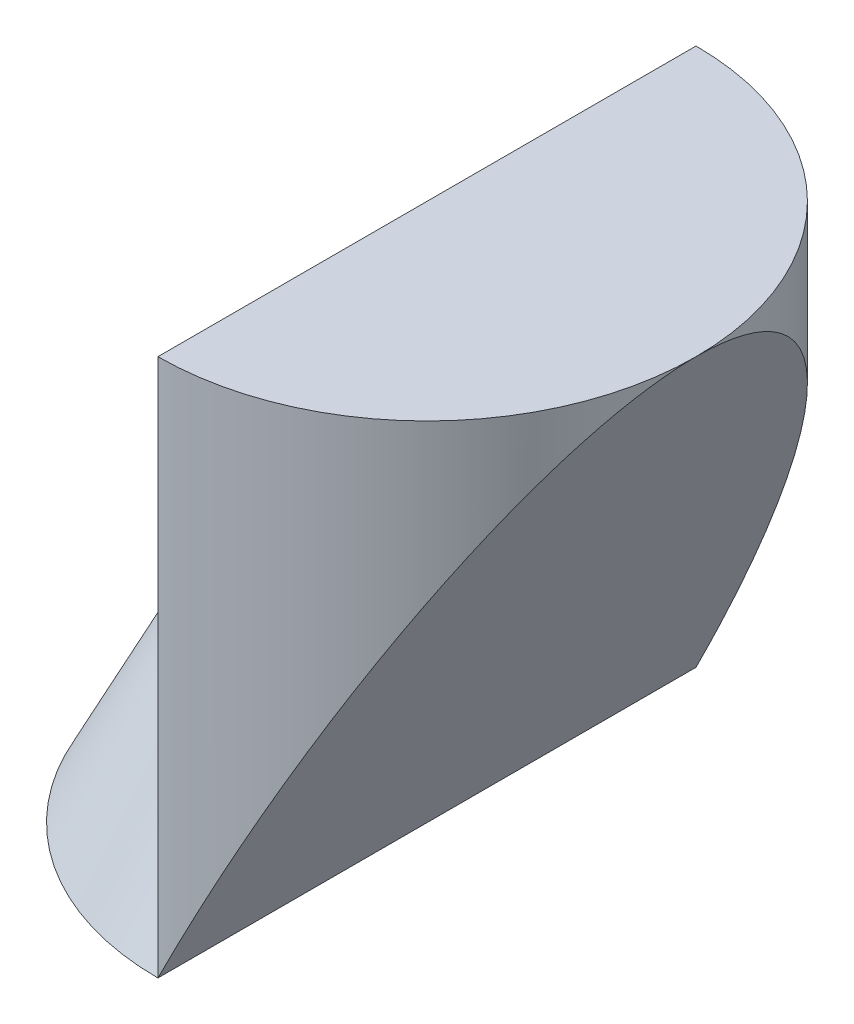
from build123d import *

# Parameters (mm, degrees)
BOSS_EXTRUDE1_DEPTH = 4
REVOLVE1_ANGLE      = 180
CUT_EXTRUDE4_DEPTH  = 4


with BuildPart() as part:
    # Sketch1 → Boss-Extrude1 (new body)
    with BuildSketch(Plane(origin=(0, 0, 0), x_dir=(1, 0, 0), z_dir=(0, 1, 0))):
        with BuildLine():
            Line((2, 0), (2, -4))
            ThreePointArc((2, -4), (4, -2), (2, 0))
        make_face()
    extrude(amount=BOSS_EXTRUDE1_DEPTH)

    # Sketch6 → Revolve1 (revolve)
    with BuildSketch(Plane.ZY.offset(-2)):
        Polygon((2, 0), (2, 4), (4, 0), align=None)
    revolve(axis=Axis((2, 0, 2), (0, -1, 0)), revolution_arc=REVOLVE1_ANGLE)

    # Sketch7 → Cut-Extrude4 (cut)
    with BuildSketch(Plane.XY):
        Polygon((4, 0), (2, 0), (4, 4), align=None)
    extrude(amount=CUT_EXTRUDE4_DEPTH, mode=Mode.SUBTRACT)


solid = part.part
